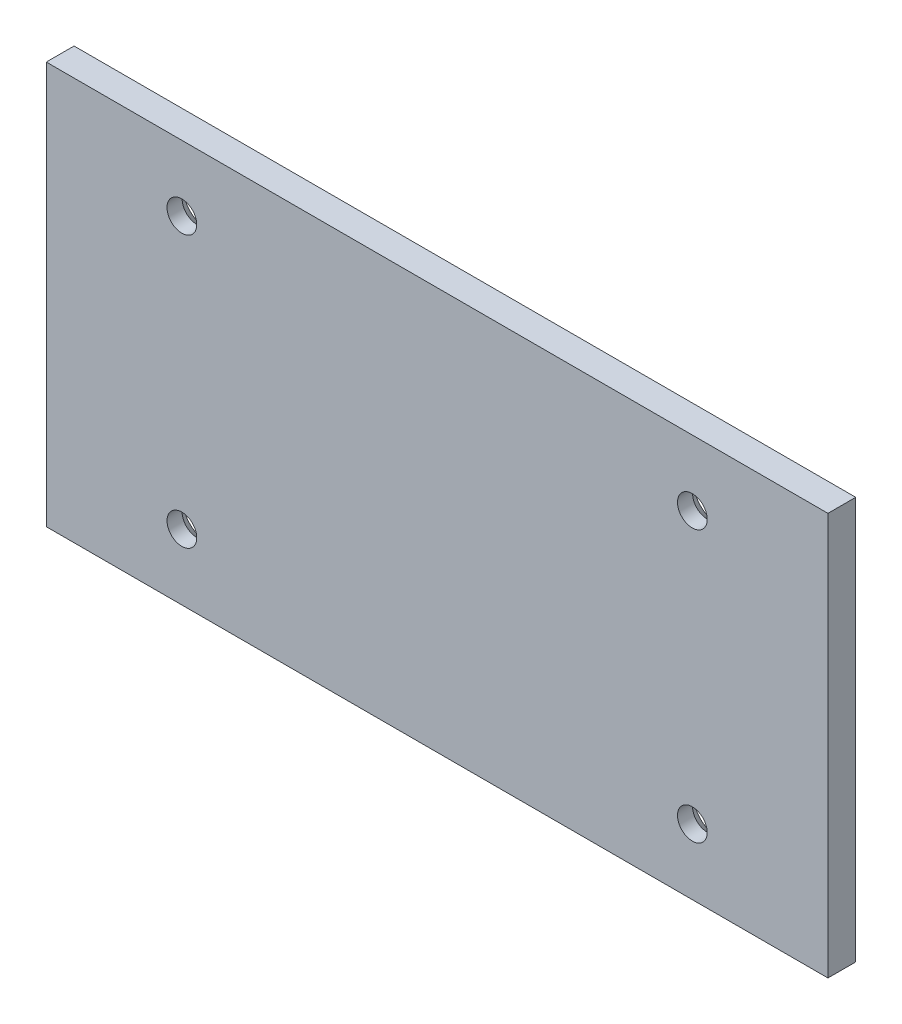
from build123d import *

# Parameters (mm, degrees)
PROFILE_SKETCH_W                                = 89.349072
PROFILE_SKETCH_H                                = 46
PROFILE_EXTRUDE_DEPTH                           = 3.175
CSK_FOR_M3_FLAT_HEAD_MACHINE_SCREW1_D           = 3.4
CSK_FOR_M3_FLAT_HEAD_MACHINE_SCREW1_CSINK_D     = 6.3
CSK_FOR_M3_FLAT_HEAD_MACHINE_SCREW1_CSINK_ANGLE = 90


with BuildPart() as part:
    # Profile Sketch → Profile Extrude (new body)
    with BuildSketch(Plane.XY):
        Rectangle(PROFILE_SKETCH_W, PROFILE_SKETCH_H)
    extrude(amount=PROFILE_EXTRUDE_DEPTH)

    # CSK for M3 Flat Head Machine Screw1 (through all)
    with Locations(Plane(origin=(-29.175456, 15.500000014, 0), x_dir=(-1, 0, 0), z_dir=(0, 0, -1))):
        with Locations((0, 0), (0, -31.000000028), (-58.350912, -31.000000028), (-58.350912, 0)):
            CounterSinkHole(CSK_FOR_M3_FLAT_HEAD_MACHINE_SCREW1_D / 2, CSK_FOR_M3_FLAT_HEAD_MACHINE_SCREW1_CSINK_D / 2, counter_sink_angle=CSK_FOR_M3_FLAT_HEAD_MACHINE_SCREW1_CSINK_ANGLE)


solid = part.part
